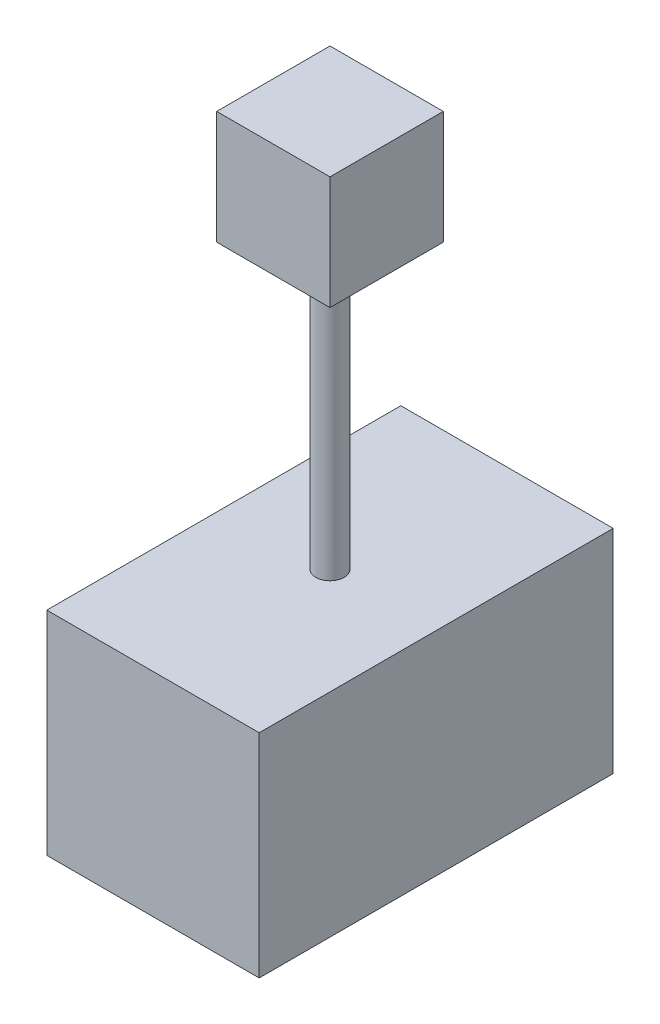
from build123d import *

# Parameters (mm, degrees)
ESQUISSE1_W      = 150
ESQUISSE1_H      = 250
EXTRUSION1_DEPTH = 150
ESQUISSE2_R      = 10
EXTRUSION2_DEPTH = 200
ESQUISSE3_W      = 80
ESQUISSE3_H      = 80
EXTRUSION3_DEPTH = 80


with BuildPart() as part:
    # Esquisse1 → Extrusion1 (new body)
    with BuildSketch(Plane(origin=(0, 0, 0), x_dir=(1, 0, 0), z_dir=(0, 1, 0))):
        with Locations((75, 125)):
            Rectangle(ESQUISSE1_W, ESQUISSE1_H)
    extrude(amount=EXTRUSION1_DEPTH)

    # Esquisse2 → Extrusion2 (add)
    with BuildSketch(Plane(origin=(0, 150, 0), x_dir=(1, 0, 0), z_dir=(0, 1, 0))):
        with Locations((75, 125)):
            Circle(ESQUISSE2_R)
    extrude(amount=EXTRUSION2_DEPTH)

    # Esquisse3 → Extrusion3 (add)
    with BuildSketch(Plane(origin=(0, 350, 0), x_dir=(1, 0, 0), z_dir=(0, 1, 0))):
        with Locations((75, 125)):
            Rectangle(ESQUISSE3_W, ESQUISSE3_H)
    extrude(amount=EXTRUSION3_DEPTH)


solid = part.part
